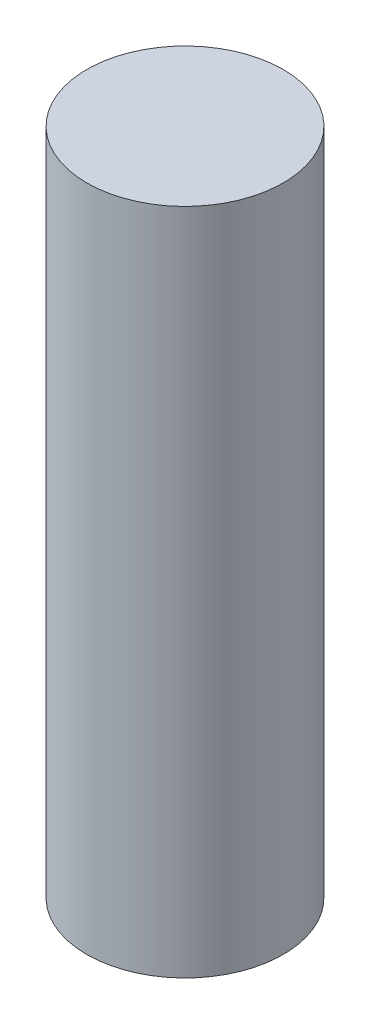
from build123d import *

# Parameters (mm, degrees)
SKETCH1_R           = 5
BOSS_EXTRUDE1_DEPTH = 34


with BuildPart() as part:
    # Sketch1 → Boss-Extrude1 (new body)
    with BuildSketch(Plane(origin=(0, 0, 0), x_dir=(1, 0, 0), z_dir=(0, 1, 0))):
        Circle(SKETCH1_R)
    extrude(amount=BOSS_EXTRUDE1_DEPTH)


solid = part.part
